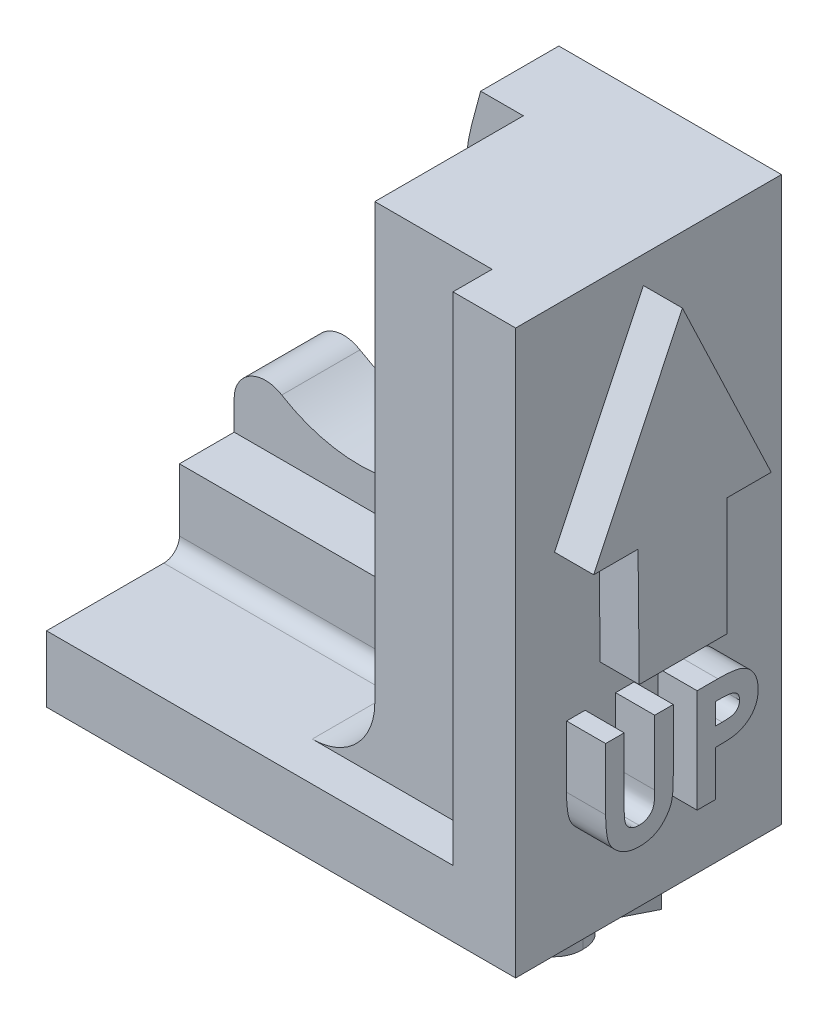
from build123d import *

# Parameters (mm, degrees)
SKETCH2_W           = 30
SKETCH2_H           = 36
BOSS_EXTRUDE1_DEPTH = 17
SKETCH3_W           = 26.993981248
SKETCH3_H           = 34.564663773
CUT_EXTRUDE1_DEPTH  = 12
CUT_EXTRUDE2_DEPTH  = 10
FILLET1_R           = 11
FILLET2_R           = 2
SKETCH5_W           = 9.5
SKETCH5_H           = 31.769582104
BOSS_EXTRUDE2_DEPTH = 7.5
SKETCH6_W           = 18.493981248
SKETCH6_H           = 5
BOSS_EXTRUDE3_DEPTH = 3.5
FILLET3_R           = 4
FILLET4_R           = 1
BOSS_EXTRUDE4_DEPTH = 2.5
BOSS_EXTRUDE5_DEPTH = 2.5


with BuildPart() as part:
    # Sketch2 → Boss-Extrude1 (new body)
    with BuildSketch(Plane.XY):
        Rectangle(SKETCH2_W, SKETCH2_H)
    extrude(amount=BOSS_EXTRUDE1_DEPTH)

    # Sketch3 → Cut-Extrude1 (cut)
    with BuildSketch(Plane.XY.offset(17)):
        with Locations((-2.503009376, 3.512749783)):
            Rectangle(SKETCH3_W, SKETCH3_H)
    extrude(amount=-CUT_EXTRUDE1_DEPTH, mode=Mode.SUBTRACT)

    # Sketch4 → Cut-Extrude2 (cut)
    with BuildSketch(Plane(origin=(0, 0, 0), x_dir=(-1, 0, 0), z_dir=(0, 0, -1))):
        with BuildLine():
            Line((-0.76246186, 18), (1.253285094, 10.477129951))
            ThreePointArc((1.253285094, 10.477129951), (8.657910243, 12.272247053), (15, 8.049828727))
            Line((15, 8.049828727), (15, 18))
            Line((15, 18), (-0.76246186, 18))
        make_face()
        with BuildLine():
            ThreePointArc((15, 8.049828727), (8.657910243, 12.272247053), (1.253285094, 10.477129951))
            ThreePointArc((1.253285094, 10.477129951), (0.561330279, -4.06271657), (15, -2.215893618))
            Line((15, -2.215893618), (15, 8.049828727))
        make_face()
        with BuildLine():
            ThreePointArc((16.506018752, 2.916967555), (16.121742033, 5.59158698), (15, 8.049828727))
            Line((15, 8.049828727), (15, -2.215893618))
            ThreePointArc((15, -2.215893618), (16.121742033, 0.242348129), (16.506018752, 2.916967555))
        make_face()
    extrude(amount=-CUT_EXTRUDE2_DEPTH, mode=Mode.SUBTRACT)

    # Fillet1
    fillet1_edges = [part.edges().sort_by_distance(p)[0] for p in [
        (-1.253285094, 10.477129951, 2.5),
    ]]
    fillet(fillet1_edges, radius=FILLET1_R)

    # Fillet2
    fillet2_edges = [part.edges().sort_by_distance(p)[0] for p in [
        (-15, -2.215893618, 2.5),
    ]]
    fillet(fillet2_edges, radius=FILLET2_R)

    # Sketch5 → Boss-Extrude2 (add)
    with BuildSketch(Plane.ZY.offset(-10.993981248)):
        with Locations((9.75, 2.115208948)):
            Rectangle(SKETCH5_W, SKETCH5_H)
    extrude(amount=BOSS_EXTRUDE2_DEPTH)

    # Sketch6 → Boss-Extrude3 (add)
    with BuildSketch(Plane.XY.offset(5)):
        with Locations((-5.753009376, -11.269582104)):
            Rectangle(SKETCH6_W, SKETCH6_H)
    extrude(amount=BOSS_EXTRUDE3_DEPTH)

    # Fillet3
    fillet3_edges = [part.edges().sort_by_distance(p)[0] for p in [
        (3.493981248, -13.769582104, 11.5),
    ]]
    fillet(fillet3_edges, radius=FILLET3_R)

    # Fillet4
    fillet4_edges = [part.edges().sort_by_distance(p)[0] for p in [
        (-7.753009376, -13.769582104, 8.5),
        (3.493981248, -9.269582104, 8.5),
        (2.322408373, -12.598009229, 8.5),
    ]]
    fillet(fillet4_edges, radius=FILLET4_R)

    # Sketch7 → Boss-Extrude4 (add)
    with BuildSketch(Plane(origin=(15, 0, 0), x_dir=(0, 0, -1), z_dir=(1, 0, 0))):
        Polygon((-11.595964768, -3.197775049), (-5.99373665, -3.197775049), (-5.99373665, 4.337103356), (-3.155192503, 4.337103356), (-8.832280797, 16.269796063), (-14.50936909, 4.337103356), (-11.670824944, 4.337103356), align=None)
        with BuildLine():
            Line((-13.74453257, -5.392399912), (-12.557299664, -5.392399912))
            Line((-12.557299664, -5.392399912), (-12.557299664, -9.696119196))
            add(Edge.make_bspline(
                [(-12.557299664, -9.696119196), (-12.557235109, -9.740738291), (-12.55711042, -9.826919611), (-12.550868423, -9.950561591), (-12.545156567, -10.064214457), (-12.534850756, -10.167753786), (-12.51962554, -10.261223867), (-12.504882564, -10.345225119), (-12.484929403, -10.418253595), (-12.454942992, -10.50137912), (-12.408743777, -10.594775187), (-12.333256823, -10.692114711), (-12.246151336, -10.780951155), (-12.141750392, -10.854895245), (-12.024412965, -10.914709349), (-11.89478377, -10.959024981), (-11.753045539, -10.983658588), (-11.655041327, -10.987419359), (-11.604598259, -10.98935504)],
                knots=[0, 0, 0, 0, 1.155499968, 2.231836252, 3.205919964, 4.102923608, 4.924856345, 5.658536265, 6.31071849, 6.882491295, 7.94666036, 8.992281882, 10.060072772, 11.158554251, 12.289267114, 13.461410017, 14.693379945, 16, 16, 16, 16], degree=3))
            add(Edge.make_bspline(
                [(-11.604598259, -10.98935504), (-11.551008724, -10.987791258), (-11.446518203, -10.984742149), (-11.296225223, -10.954811844), (-11.156977925, -10.907152547), (-11.031724648, -10.839130585), (-10.920590041, -10.757594342), (-10.826516925, -10.664617474), (-10.752274767, -10.560014538), (-10.703886491, -10.463510364), (-10.676718857, -10.374686676), (-10.656355361, -10.295326081), (-10.641426667, -10.201688435), (-10.627882864, -10.095236091), (-10.619744082, -9.974866408), (-10.6109189, -9.841547414), (-10.607684389, -9.694366906), (-10.60713309, -9.591882356), (-10.606845605, -9.538439825)],
                knots=[0, 0, 0, 0, 1.261321664, 2.459363699, 3.594844139, 4.716940403, 5.803436589, 6.833651888, 7.818396249, 8.814403945, 9.360733334, 10.004355033, 10.743453831, 11.592799886, 12.532235708, 13.585170094, 14.740740724, 16, 16, 16, 16], degree=3))
            Line((-10.606845605, -9.538439825), (-10.606845605, -5.392399912))
            Line((-10.606845605, -5.392399912), (-9.419612699, -5.392399912))
            Line((-9.419612699, -5.392399912), (-9.419612699, -9.33835928))
            add(Edge.make_bspline(
                [(-9.419612699, -9.33835928), (-9.419777568, -9.418304228), (-9.420094594, -9.572030567), (-9.424963169, -9.792946133), (-9.435327485, -9.994717067), (-9.444032315, -10.177402325), (-9.460879142, -10.340755799), (-9.478429583, -10.485475057), (-9.500799131, -10.611047244), (-9.534083673, -10.75399592), (-9.591522938, -10.918596084), (-9.684122563, -11.108126038), (-9.801671795, -11.293687343), (-9.940609112, -11.473238698), (-10.097482052, -11.64003612), (-10.268812405, -11.786462666), (-10.45187816, -11.910323734), (-10.648592221, -12.008590773), (-10.858787175, -12.085231655), (-11.084542743, -12.136730467), (-11.32570498, -12.171523711), (-11.492280294, -12.17486603), (-11.578097524, -12.176587946)],
                knots=[0, 0, 0, 0, 1.170808336, 2.251350247, 3.235597562, 4.129743112, 4.929140599, 5.639994148, 6.264258765, 6.79612947, 7.788252245, 8.809469599, 9.879094798, 10.999557536, 12.129761673, 13.226370002, 14.293821979, 15.358369427, 16.438775801, 17.562147481, 18.744053101, 20, 20, 20, 20], degree=3))
            add(Edge.make_bspline(
                [(-11.578097524, -12.176587946), (-11.635116199, -12.175627541), (-11.747612875, -12.173732684), (-11.913058972, -12.157024986), (-12.072995124, -12.132404123), (-12.227120814, -12.096484818), (-12.375970981, -12.050083786), (-12.519506081, -11.992967346), (-12.657192702, -11.925454088), (-12.788260369, -11.848164987), (-12.912547792, -11.764590129), (-13.026140082, -11.67194388), (-13.132946214, -11.577077782), (-13.229880605, -11.475999465), (-13.317671319, -11.36977008), (-13.39613755, -11.258148875), (-13.465162723, -11.141145766), (-13.526483129, -11.016651779), (-13.578967412, -10.878339333), (-13.623213634, -10.721288597), (-13.661868175, -10.543037959), (-13.690593949, -10.34318583), (-13.716636904, -10.122390898), (-13.733120659, -9.880077961), (-13.741744053, -9.616240065), (-13.743579578, -9.433326722), (-13.74453257, -9.33835928)],
                knots=[0, 0, 0, 0, 1.001158378, 1.975264943, 2.917723546, 3.841610987, 4.75185031, 5.653588123, 6.552117133, 7.442167995, 8.324307438, 9.179605724, 10.014504199, 10.831958861, 11.636465792, 12.43274043, 13.225645099, 14.020104002, 14.867201867, 15.819789774, 16.883317127, 18.068162734, 19.364263498, 20.787406516, 22.332041935, 24, 24, 24, 24], degree=3))
            Line((-13.74453257, -9.33835928), (-13.74453257, -5.392399912))
        make_face()
        with BuildLine():
            Line((-7.893170391, -5.392399912), (-6.568133666, -5.392399912))
            add(Edge.make_bspline(
                [(-6.568133666, -5.392399912), (-6.481557485, -5.392787445), (-6.314533885, -5.393535078), (-6.073672112, -5.402601125), (-5.851465333, -5.418848033), (-5.6479646, -5.438926642), (-5.463253588, -5.467076071), (-5.297100982, -5.499347187), (-5.149472302, -5.538662799), (-5.018702815, -5.585329885), (-4.901341425, -5.640348557), (-4.790279697, -5.698947369), (-4.688027639, -5.768882985), (-4.58942428, -5.84261804), (-4.500106946, -5.927196417), (-4.414503485, -6.016989301), (-4.336239437, -6.115557805), (-4.264952157, -6.221708784), (-4.200283609, -6.33348102), (-4.143784839, -6.451074331), (-4.097956201, -6.574674794), (-4.059511673, -6.703482855), (-4.028632653, -6.837492901), (-4.008078594, -6.977529106), (-3.994117243, -7.122613683), (-3.992885347, -7.221358338), (-3.992262271, -7.271301988)],
                knots=[0, 0, 0, 0, 1.698747864, 3.27724071, 4.728299578, 6.070144658, 7.288476769, 8.393259625, 9.389771311, 10.283485332, 11.113357557, 11.931608583, 12.74405601, 13.541433047, 14.344816069, 15.154114104, 15.974336324, 16.810834471, 17.661136416, 18.50621059, 19.367396281, 20.244825668, 21.142564693, 22.063065223, 23.020325768, 24, 24, 24, 24], degree=3))
            add(Edge.make_bspline(
                [(-3.992262271, -7.271301988), (-3.993163784, -7.32655346), (-3.994935367, -7.435129391), (-4.012302591, -7.594288385), (-4.041971297, -7.746032076), (-4.080746744, -7.891640145), (-4.134816347, -8.028717017), (-4.196588329, -8.160533389), (-4.272587461, -8.283393533), (-4.359428619, -8.398834282), (-4.45426907, -8.507794225), (-4.559360324, -8.607127348), (-4.672699295, -8.697510802), (-4.793629905, -8.779891813), (-4.922606163, -8.854104199), (-5.059535007, -8.920842882), (-5.205351465, -8.977973351), (-5.306893659, -9.007852124), (-5.358375135, -9.023000539)],
                knots=[0, 0, 0, 0, 1.102006807, 2.165578795, 3.188629044, 4.184801286, 5.166646146, 6.124351954, 7.085497154, 8.042432466, 9.003981491, 9.963833307, 10.922997304, 11.89326795, 12.880200226, 13.889073926, 14.929769137, 16, 16, 16, 16], degree=3))
            add(Edge.make_bspline(
                [(-5.358375135, -9.023000539), (-5.392283797, -9.031437069), (-5.465740877, -9.049713309), (-5.587292168, -9.068268281), (-5.72736727, -9.085328436), (-5.886419135, -9.099989574), (-6.064539462, -9.109955732), (-6.261555783, -9.117738857), (-6.477557382, -9.123397994), (-6.627756353, -9.123598805), (-6.705937485, -9.12370333)],
                knots=[0, 0, 0, 0, 0.618981996, 1.340914327, 2.176866532, 3.120127938, 4.170906482, 5.338178032, 6.614476169, 8, 8, 8, 8], degree=3))
            Line((-6.705937485, -9.12370333), (-6.705937485, -12.006983245))
            Line((-6.705937485, -12.006983245), (-7.893170391, -12.006983245))
            Line((-7.893170391, -12.006983245), (-7.893170391, -5.392399912))
        make_face()
        with BuildLine():
            Line((-6.705937485, -7.936470424), (-6.285900843, -7.936470424))
            add(Edge.make_bspline(
                [(-6.285900843, -7.936470424), (-6.209468545, -7.935985784), (-6.06883198, -7.935094039), (-5.876772096, -7.922198889), (-5.722429079, -7.902505389), (-5.600495229, -7.874260356), (-5.504216906, -7.831394778), (-5.42118288, -7.781807376), (-5.349962475, -7.719105468), (-5.288296088, -7.647457809), (-5.23899567, -7.565131059), (-5.204808397, -7.473465747), (-5.182601018, -7.374387861), (-5.18054996, -7.30543621), (-5.179495177, -7.269976951)],
                knots=[0, 0, 0, 0, 1.8619151, 3.425951444, 4.686033666, 5.651700536, 6.461346321, 7.243864085, 7.999046032, 8.762387399, 9.539336099, 10.322741239, 11.137448474, 12, 12, 12, 12], degree=3))
            add(Edge.make_bspline(
                [(-5.179495177, -7.269976951), (-5.18053911, -7.238996659), (-5.18256459, -7.178887444), (-5.197444318, -7.092134936), (-5.221158325, -7.011263702), (-5.255519009, -6.937118336), (-5.299939237, -6.869824822), (-5.354096484, -6.80940967), (-5.417295807, -6.754579037), (-5.466089379, -6.725556345), (-5.490878808, -6.710811453)],
                knots=[0, 0, 0, 0, 1.102301479, 2.1387299, 3.123554645, 4.094223062, 5.036071848, 5.982632524, 6.975082478, 8, 8, 8, 8], degree=3))
            add(Edge.make_bspline(
                [(-5.490878808, -6.710811453), (-5.511876885, -6.700192124), (-5.556334117, -6.677708827), (-5.632049093, -6.65157035), (-5.719423019, -6.629519666), (-5.819045768, -6.61121781), (-5.930519916, -6.59701367), (-6.053825574, -6.586151056), (-6.189144197, -6.581782776), (-6.283250203, -6.580369237), (-6.332277128, -6.579632817)],
                knots=[0, 0, 0, 0, 0.656809284, 1.390599849, 2.23162475, 3.173112763, 4.218524733, 5.370385145, 6.63003504, 8, 8, 8, 8], degree=3))
            Line((-6.332277128, -6.579632817), (-6.705937485, -6.579632817))
            Line((-6.705937485, -6.579632817), (-6.705937485, -7.936470424))
        make_face(mode=Mode.SUBTRACT)
    extrude(amount=BOSS_EXTRUDE4_DEPTH)

    # Sketch8 → Boss-Extrude5 (add)
    with BuildSketch(Plane.XZ.offset(18)):
        Polygon((-14.236778846, 12.653071873), (-11.01428953, 12.653071873), (-11.01428953, 11.465838967), (-13.04954594, 11.465838967), (-13.04954594, 10.19380371), (-11.01428953, 10.19380371), (-11.01428953, 9.006570804), (-13.04954594, 9.006570804), (-13.04954594, 6.038488539), (-14.236778846, 6.038488539), align=None)
        Polygon((-9.827056624, 12.653071873), (-6.265357906, 12.653071873), (-6.265357906, 11.465838967), (-8.639823718, 11.465838967), (-8.639823718, 10.19380371), (-6.265357906, 10.19380371), (-6.265357906, 9.006570804), (-8.639823718, 9.006570804), (-8.639823718, 7.225721445), (-6.265357906, 7.225721445), (-6.265357906, 6.038488539), (-9.827056624, 6.038488539), align=None)
        Polygon((-4.554735493, 12.653071873), (-3.322451339, 12.653071873), (-1.813234509, 8.039293995), (-0.293417384, 12.653071873), (0.92694144, 12.653071873), (2.045272436, 6.038488539), (0.843464126, 6.038488539), (0.137219551, 10.216329335), (-1.23816857, 6.038488539), (-2.396250668, 6.038488539), (-3.763688568, 10.216329335), (-4.468608106, 6.038488539), (-5.671741453, 6.038488539), align=None)
        with BuildLine():
            Line((3.147702991, 12.653071873), (4.334935897, 12.653071873))
            Line((4.334935897, 12.653071873), (4.334935897, 8.349352588))
            add(Edge.make_bspline(
                [(4.334935897, 8.349352588), (4.335000453, 8.304733494), (4.335125142, 8.218552173), (4.341367138, 8.094910194), (4.347078995, 7.981257327), (4.357384806, 7.877717998), (4.372610022, 7.784247917), (4.387352998, 7.700246665), (4.407306159, 7.627218189), (4.43729257, 7.544092664), (4.483491785, 7.450696597), (4.558978739, 7.353357073), (4.646084226, 7.264520629), (4.75048517, 7.190576539), (4.867822597, 7.130762435), (4.997451792, 7.086446803), (5.139190023, 7.061813196), (5.237194235, 7.058052425), (5.287637303, 7.056116744)],
                knots=[0, 0, 0, 0, 1.155499968, 2.231836252, 3.205919964, 4.102923608, 4.924856345, 5.658536265, 6.31071849, 6.882491295, 7.94666036, 8.992281882, 10.060072772, 11.158554251, 12.289267114, 13.461410017, 14.693379945, 16, 16, 16, 16], degree=3))
            add(Edge.make_bspline(
                [(5.287637303, 7.056116744), (5.341226838, 7.057680526), (5.445717359, 7.060729635), (5.596010339, 7.09065994), (5.735257637, 7.138319237), (5.860510913, 7.206341199), (5.971645521, 7.287877442), (6.065718637, 7.380854311), (6.139960795, 7.485457246), (6.188349071, 7.58196142), (6.215516705, 7.670785108), (6.2358802, 7.750145703), (6.250808895, 7.84378335), (6.264352698, 7.950235694), (6.27249148, 8.070605377), (6.281316662, 8.20392437), (6.284551173, 8.351104878), (6.285102472, 8.453589429), (6.285389957, 8.507031959)],
                knots=[0, 0, 0, 0, 1.261321664, 2.459363699, 3.594844139, 4.716940403, 5.803436589, 6.833651888, 7.818396249, 8.814403945, 9.360733334, 10.004355033, 10.743453831, 11.592799886, 12.532235708, 13.585170094, 14.740740724, 16, 16, 16, 16], degree=3))
            Line((6.285389957, 8.507031959), (6.285389957, 12.653071873))
            Line((6.285389957, 12.653071873), (7.472622863, 12.653071873))
            Line((7.472622863, 12.653071873), (7.472622863, 8.707112504))
            add(Edge.make_bspline(
                [(7.472622863, 8.707112504), (7.472457994, 8.627167556), (7.472140968, 8.473441217), (7.467272392, 8.252525651), (7.456908077, 8.050754717), (7.448203247, 7.868069459), (7.43135642, 7.704715985), (7.413805979, 7.559996728), (7.391436431, 7.43442454), (7.358151889, 7.291475865), (7.300712624, 7.1268757), (7.208112999, 6.937345746), (7.090563767, 6.751784441), (6.95162645, 6.572233086), (6.79475351, 6.405435665), (6.623423156, 6.259009118), (6.440357402, 6.13514805), (6.243643341, 6.036881011), (6.033448387, 5.96024013), (5.807692819, 5.908741317), (5.566530582, 5.873948073), (5.399955267, 5.870605754), (5.314138038, 5.868883838)],
                knots=[0, 0, 0, 0, 1.170808336, 2.251350247, 3.235597562, 4.129743112, 4.929140599, 5.639994148, 6.264258765, 6.79612947, 7.788252245, 8.809469599, 9.879094798, 10.999557536, 12.129761673, 13.226370002, 14.293821979, 15.358369427, 16.438775801, 17.562147481, 18.744053101, 20, 20, 20, 20], degree=3))
            add(Edge.make_bspline(
                [(5.314138038, 5.868883838), (5.257119363, 5.869844243), (5.144622687, 5.871739101), (4.97917659, 5.888446798), (4.819240437, 5.913067662), (4.665114748, 5.948986966), (4.516264581, 5.995387998), (4.372729481, 6.052504438), (4.23504286, 6.120017696), (4.103975193, 6.197306798), (3.979687769, 6.280881656), (3.86609548, 6.373527904), (3.759289348, 6.468394002), (3.662354956, 6.569472319), (3.574564243, 6.675701705), (3.496098012, 6.787322909), (3.427072839, 6.904326018), (3.365752433, 7.028820005), (3.31326815, 7.167132452), (3.269021928, 7.324183187), (3.230367387, 7.502433825), (3.201641613, 7.702285954), (3.175598658, 7.923080886), (3.159114903, 8.165393823), (3.150491509, 8.429231719), (3.148655984, 8.612145062), (3.147702991, 8.707112504)],
                knots=[0, 0, 0, 0, 1.001158378, 1.975264943, 2.917723546, 3.841610987, 4.75185031, 5.653588123, 6.552117133, 7.442167995, 8.324307438, 9.179605724, 10.014504199, 10.831958861, 11.636465792, 12.43274043, 13.225645099, 14.020104002, 14.867201867, 15.819789774, 16.883317127, 18.068162734, 19.364263498, 20.787406516, 22.332041935, 24, 24, 24, 24], degree=3))
            Line((3.147702991, 8.707112504), (3.147702991, 12.653071873))
        make_face()
        with BuildLine():
            Line((8.999065171, 12.653071873), (10.382403512, 12.653071873))
            add(Edge.make_bspline(
                [(10.382403512, 12.653071873), (10.473841756, 12.652747319), (10.649703254, 12.652123112), (10.90328593, 12.642274773), (11.136236491, 12.628570001), (11.348899841, 12.607656154), (11.541185, 12.579926922), (11.713284683, 12.547238746), (11.865193859, 12.509983561), (11.998193672, 12.463560661), (12.118219426, 12.411196334), (12.230100116, 12.351028763), (12.336303996, 12.283727931), (12.436121207, 12.207522972), (12.530419185, 12.123784794), (12.619375829, 12.032429108), (12.701734098, 11.932681253), (12.776984027, 11.82517151), (12.84556828, 11.712073726), (12.906182376, 11.593232617), (12.955473858, 11.468565536), (12.999028168, 11.339874193), (13.030398925, 11.20531892), (13.052216829, 11.066209634), (13.068191044, 10.922056657), (13.069109485, 10.824125524), (13.069577991, 10.774169796)],
                knots=[0, 0, 0, 0, 1.749336639, 3.364467119, 4.854658419, 6.213483162, 7.451590619, 8.570285859, 9.5643256, 10.440900261, 11.26203566, 12.067320669, 12.869050712, 13.665104639, 14.467235401, 15.27997916, 16.102287765, 16.939272006, 17.78853747, 18.631303466, 19.488103222, 20.351255419, 21.228522269, 22.127379805, 23.044756219, 24, 24, 24, 24], degree=3))
            add(Edge.make_bspline(
                [(13.069577991, 10.774169796), (13.06836098, 10.722027492), (13.065974641, 10.619785937), (13.053120524, 10.469601431), (13.029627236, 10.325915401), (12.994043234, 10.189148542), (12.953144045, 10.05759863), (12.898758614, 9.933692844), (12.837379281, 9.815629153), (12.764480841, 9.705077614), (12.684478363, 9.599582655), (12.591437165, 9.503186181), (12.491384886, 9.410707244), (12.378697224, 9.327938413), (12.258341556, 9.249283158), (12.12792654, 9.17800055), (11.98830331, 9.112298709), (11.890141265, 9.075658824), (11.83994391, 9.0569222)],
                knots=[0, 0, 0, 0, 1.099860209, 2.156625411, 3.176576793, 4.16617041, 5.135385252, 6.078461593, 7.016046972, 7.938469504, 8.868247731, 9.803980173, 10.76021508, 11.73834243, 12.748633912, 13.790971185, 14.870363756, 16, 16, 16, 16], degree=3))
            Line((11.83994391, 9.0569222), (13.366386218, 6.038488539))
            Line((13.366386218, 6.038488539), (12.046649639, 6.038488539))
            Line((12.046649639, 6.038488539), (10.589109241, 8.921768454))
            Line((10.589109241, 8.921768454), (10.186298077, 8.921768454))
            Line((10.186298077, 8.921768454), (10.186298077, 6.038488539))
            Line((10.186298077, 6.038488539), (8.999065171, 6.038488539))
            Line((8.999065171, 6.038488539), (8.999065171, 12.653071873))
        make_face()
        with BuildLine():
            Line((10.186298077, 10.10900136), (10.648735894, 10.10900136))
            add(Edge.make_bspline(
                [(10.648735894, 10.10900136), (10.705272761, 10.109638116), (10.813528714, 10.110857367), (10.969214992, 10.11651276), (11.110615261, 10.130139463), (11.238336743, 10.147356292), (11.35302212, 10.167235607), (11.453648438, 10.195723873), (11.541766197, 10.226249772), (11.616331196, 10.264185545), (11.680037819, 10.307326747), (11.735044409, 10.356336225), (11.780542747, 10.413058455), (11.8179902, 10.475951972), (11.847120247, 10.545573054), (11.868382949, 10.621157418), (11.880265655, 10.703566068), (11.881632801, 10.760439257), (11.882345085, 10.790070237)],
                knots=[0, 0, 0, 0, 1.688639943, 3.233382647, 4.650958383, 5.928841754, 7.082724185, 8.122798841, 9.049171256, 9.863274652, 10.613301712, 11.341792392, 12.054588806, 12.776240173, 13.521029143, 14.301969904, 15.115324896, 16, 16, 16, 16], degree=3))
            add(Edge.make_bspline(
                [(11.882345085, 10.790070237), (11.880998447, 10.825125849), (11.878353225, 10.893986102), (11.852104409, 10.993120721), (11.810321963, 11.084876594), (11.753049674, 11.168839144), (11.680922672, 11.242446512), (11.598151247, 11.307331993), (11.50294899, 11.358638577), (11.414798865, 11.392479853), (11.334602856, 11.412727437), (11.262228487, 11.427815758), (11.178418533, 11.438509284), (11.08310972, 11.449851672), (10.976544995, 11.457206637), (10.858143516, 11.462574295), (10.728245332, 11.464770468), (10.63769396, 11.465472545), (10.590434278, 11.465838967)],
                knots=[0, 0, 0, 0, 1.020303359, 2.004196876, 2.966617323, 3.9489082, 4.950758222, 5.960522915, 7.003732012, 8.091992268, 8.70421221, 9.413913587, 10.24622431, 11.166358409, 12.212345909, 13.359657661, 14.621978493, 16, 16, 16, 16], degree=3))
            Line((10.590434278, 11.465838967), (10.186298077, 11.465838967))
            Line((10.186298077, 11.465838967), (10.186298077, 10.10900136))
        make_face(mode=Mode.SUBTRACT)
    extrude(amount=BOSS_EXTRUDE5_DEPTH)


solid = part.part
